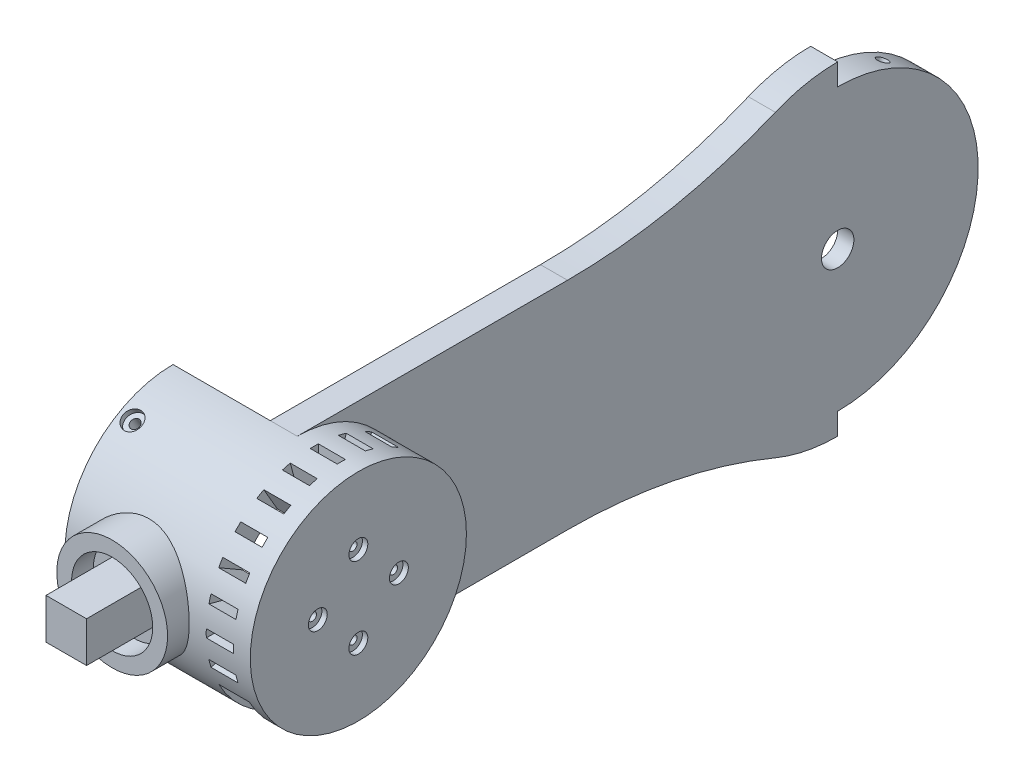
from build123d import *
from build123d.topology import SkipClean

# Parameters (mm, degrees)
SKETCH1_R                                            = 60
SKETCH1_R_2                                          = 45
SKETCH1_R_3                                          = 40
BOSS_EXTRUDE3_DEPTH                                  = 10
SKETCH5_R                                            = 30
CUT_EXTRUDE2_DEPTH                                   = 248.588368063
CUT_EXTRUDE2_DEPTH_BACK                              = 248.588368063
SKETCH6_R                                            = 18.5
CUT_EXTRUDE3_DEPTH                                   = 4
SKETCH7_R                                            = 40
SKETCH7_R_2                                          = 30
BOSS_EXTRUDE4_DEPTH                                  = 17.6
SKETCH8_R                                            = 40
BOSS_EXTRUDE5_DEPTH                                  = 5
SKETCH9_R                                            = 1.5
CUT_EXTRUDE4_DEPTH                                   = 249.921192348
CUT_EXTRUDE4_DEPTH_BACK                              = 249.921192348
BOSS_EXTRUDE6_DEPTH                                  = 31
BOSS_EXTRUDE8_REACH                                  = 309.673
SKETCH13_R                                           = 20.5
SKETCH16_W                                           = 15
SKETCH16_H                                           = 15
BOSS_EXTRUDE11_DEPTH                                 = 25
SKETCH17_R                                           = 15
BOSS_EXTRUDE12_DEPTH                                 = 8
SKETCH21_R                                           = 3.5
CUT_EXTRUDE5_DEPTH                                   = 2
BOSS_EXTRUDE13_DEPTH                                 = 5
CUT_EXTRUDE6_DEPTH                                   = 275.082104487
CBORE_FOR_M3_HEXAGON_HEAD_BOLTS_FULL_THR_D           = 3.4
CBORE_FOR_M3_HEXAGON_HEAD_BOLTS_FULL_THR_CBORE_D     = 7
CBORE_FOR_M3_HEXAGON_HEAD_BOLTS_FULL_THR_CBORE_DEPTH = 2
CBORE_FOR_M3_HEXAGON_HEAD_BOLTS_FULL_2_D             = 3.4
CBORE_FOR_M3_HEXAGON_HEAD_BOLTS_FULL_2_CBORE_D       = 7
CBORE_FOR_M3_HEXAGON_HEAD_BOLTS_FULL_2_CBORE_DEPTH   = 2
SKETCH33_R                                           = 2.05
CUT_EXTRUDE14_DEPTH                                  = 13
SKETCH34_R                                           = 2.05
CUT_EXTRUDE15_DEPTH                                  = 13
F_4_0MM_DOWEL_HOLE1_D                                = 4.1
F_4_0MM_DOWEL_HOLE1_DEPTH                            = 7
F_4_0MM_DOWEL_HOLE1_TIP                              = 1.231764269
F_4_0MM_DOWEL_HOLE1_ON_FACE_2_D                      = 4.1
F_4_0MM_DOWEL_HOLE1_ON_FACE_2_DEPTH                  = 7
F_4_0MM_DOWEL_HOLE1_ON_FACE_2_TIP                    = 1.231764269
SKETCH36_R                                           = 6
CUT_EXTRUDE16_DEPTH                                  = 2.5
CUT_EXTRUDE17_REACH                                  = 310.052
CUT_EXTRUDE17_END_RADIUS                             = 30
SKETCH37_W                                           = 10
SKETCH37_H                                           = 3
CIRPATTERN1_COUNT                                    = 24
CUT_EXTRUDE19_REACH                                  = 302.391
CUT_EXTRUDE19_END_RADIUS                             = 30
SKETCH39_W                                           = 11.3
SKETCH39_H                                           = 35
CUT_EXTRUDE20_REACH                                  = 255.253
CUT_EXTRUDE20_END_RADIUS                             = 30
SKETCH40_W                                           = 27.398821822
SKETCH40_H                                           = 15
CUT_EXTRUDE20_DIRECTION_2_REACH                      = 255.253
CUT_EXTRUDE20_DIRECTION_2_END_RADIUS                 = 34
CUT_EXTRUDE21_REACH                                  = 276.636
SKETCH41_R                                           = 6


with BuildPart() as part:
    # Sketch1 → Boss-Extrude3 (new body)
    with BuildSketch(Plane(origin=(0, 0, 0), x_dir=(0, 0, -1), z_dir=(1, 0, 0))):
        Circle(SKETCH1_R)
        Circle(SKETCH1_R_2, mode=Mode.SUBTRACT)
        with BuildLine():
            ThreePointArc((-23.076923077, 55.384615385), (-60.776772972, 43.883864862), (-100, 40))
            Line((-100, 40), (-200, 40))
            ThreePointArc((-200, 40), (-171.715728753, 28.284271247), (-160, 0))
            ThreePointArc((-160, 0), (-171.715728753, -28.284271247), (-200, -40))
            Line((-200, -40), (-100, -40))
            ThreePointArc((-100, -40), (-60.776772972, -43.883864862), (-23.076923077, -55.384615385))
            ThreePointArc((-23.076923077, -55.384615385), (-60, 0), (-23.076923077, 55.384615385))
        make_face()
        with Locations((-200, 0)):
            Circle(SKETCH1_R_3)
        Circle(SKETCH1_R_2)
    extrude(amount=BOSS_EXTRUDE3_DEPTH)

    # Sketch5 → Cut-Extrude2 (cut, two sides)
    with BuildSketch(Plane(origin=(10, 0, 0), x_dir=(0, 0, -1), z_dir=(1, 0, 0))) as cut_extrude2_sk:
        with Locations((-200, 0)):
            Circle(SKETCH5_R)
    extrude(amount=CUT_EXTRUDE2_DEPTH, mode=Mode.SUBTRACT)
    extrude(cut_extrude2_sk.sketch, amount=-CUT_EXTRUDE2_DEPTH_BACK, mode=Mode.SUBTRACT)

    # Sketch6 → Cut-Extrude3 (cut)
    with BuildSketch(Plane.ZY):
        Circle(SKETCH6_R)
    extrude(amount=-CUT_EXTRUDE3_DEPTH, mode=Mode.SUBTRACT)

    # Sketch7 → Boss-Extrude4 (add)
    with BuildSketch(Plane(origin=(10, 0, 0), x_dir=(0, 0, -1), z_dir=(1, 0, 0))):
        with Locations(Location((-200, 0, 0), (0, 0, 270))):
            Circle(SKETCH7_R)
        with Locations((-200, 0)):
            Circle(SKETCH7_R_2, mode=Mode.SUBTRACT)
    extrude(amount=BOSS_EXTRUDE4_DEPTH)

    # Sketch8 → Boss-Extrude5 (add)
    with BuildSketch(Plane(origin=(27.6, 0, 0), x_dir=(0, 0, -1), z_dir=(1, 0, 0))):
        with Locations(Location((-200, 0, 0), (0, 0, 270))):
            Circle(SKETCH8_R)
    extrude(amount=BOSS_EXTRUDE5_DEPTH)

    # Sketch9 → Cut-Extrude4 (cut, two sides)
    with BuildSketch(Plane.ZY.offset(-27.6)) as cut_extrude4_sk:
        with Locations((200, 15)):
            Circle(SKETCH9_R)
        with Locations((215, 0)):
            Circle(SKETCH9_R)
        with Locations((200, -15)):
            Circle(SKETCH9_R)
        with Locations((185, 0)):
            Circle(SKETCH9_R)
    extrude(amount=CUT_EXTRUDE4_DEPTH, mode=Mode.SUBTRACT)
    extrude(cut_extrude4_sk.sketch, amount=-CUT_EXTRUDE4_DEPTH_BACK, mode=Mode.SUBTRACT)

    # Sketch10 → Boss-Extrude6 (add)
    with BuildSketch(Plane.ZY):
        with BuildLine():
            Line((200, 40), (200, 30))
            ThreePointArc((200, 30), (230, 0), (200, -30))
            Line((200, -30), (200, -40))
            ThreePointArc((200, -40), (240, 0), (200, 40))
        make_face()
    extrude(amount=BOSS_EXTRUDE6_DEPTH)

    # Sketch13 → Boss-Extrude8 (add, up to next)
    with BuildSketch(Plane.XY.offset(240), mode=Mode.PRIVATE) as boss_extrude8_sk1:
        with Locations((-10.5, 0)):
            Circle(SKETCH13_R)
    boss_extrude8_tool1 = extrude(boss_extrude8_sk1.sketch, amount=-BOSS_EXTRUDE8_REACH, mode=Mode.PRIVATE) - part.part
    add(boss_extrude8_tool1.solids().sort_by_distance((-10.5, 0, 240))[0])
    add(boss_extrude8_tool1.solids().sort_by_distance((-10.5, 0, 240))[1])

    # Sketch16 → Boss-Extrude11 (add)
    with BuildSketch(Plane.XY.offset(240)):
        with Locations((-10.5, 0)):
            Rectangle(SKETCH16_W, SKETCH16_H)
    extrude(amount=BOSS_EXTRUDE11_DEPTH)

    # Sketch17 → Boss-Extrude12 (add)
    with BuildSketch(Plane.XY.offset(240)):
        with BuildLine():
            ThreePointArc((-31, 0), (-10.5, -20.5), (10, 0))
            ThreePointArc((10, 0), (-10.5, 20.5), (-31, 0))
        make_face()
        with Locations((-10.5, 0)):
            Circle(SKETCH17_R, mode=Mode.SUBTRACT)
    extrude(amount=BOSS_EXTRUDE12_DEPTH)

    # Sketch21 → Cut-Extrude5 (cut)
    with BuildSketch(Plane(origin=(32.6, 0, 0), x_dir=(0, 0, -1), z_dir=(1, 0, 0))):
        with Locations((-200, -15)):
            Circle(SKETCH21_R)
        with Locations((-215, 0)):
            Circle(SKETCH21_R)
        with Locations((-200, 15)):
            Circle(SKETCH21_R)
        with Locations((-185, 0)):
            Circle(SKETCH21_R)
    extrude(amount=-CUT_EXTRUDE5_DEPTH, mode=Mode.SUBTRACT)

    # Sketch23 → Boss-Extrude13 (add)
    with BuildSketch(Plane.ZY.offset(31)):
        with BuildLine():
            Line((200, 40), (200, 30))
            ThreePointArc((200, 30), (230, 0), (200, -30))
            Line((200, -30), (200, -40))
            ThreePointArc((200, -40), (228.284271247, -28.284271247), (240, 0))
            ThreePointArc((240, 0), (228.284271247, 28.284271247), (200, 40))
        make_face()
    extrude(amount=BOSS_EXTRUDE13_DEPTH)

    # Sketch24 → Cut-Extrude6 (cut, through all)
    with BuildSketch(Plane.ZY):
        with BuildLine():
            Line((0, 52), (0, 60))
            ThreePointArc((0, 60), (-60, 0), (0, -60))
            Line((0, -60), (0, -52))
            ThreePointArc((0, -52), (-52, 0), (0, 52))
        make_face()
    extrude(amount=-CUT_EXTRUDE6_DEPTH, mode=Mode.SUBTRACT)

    # CBORE for M3 Hexagon head bolts-Full thr (through all)
    with Locations(Plane(origin=(-31, 34.641016151, 220), x_dir=(0, -0.5, 0.866025403784), z_dir=(0, 0.866025403784, 0.5))):
        with Locations((0, 0)):
            CounterBoreHole(CBORE_FOR_M3_HEXAGON_HEAD_BOLTS_FULL_THR_D / 2, CBORE_FOR_M3_HEXAGON_HEAD_BOLTS_FULL_THR_CBORE_D / 2, CBORE_FOR_M3_HEXAGON_HEAD_BOLTS_FULL_THR_CBORE_DEPTH)

    # CBORE for M3 Hexagon head bolts-Full 2 (through all)
    with Locations(Plane(origin=(-31, -34.641016151, 220), x_dir=(0, -0.500000174844, -0.866025302838), z_dir=(0, -0.866025302838, 0.500000174844))):
        with Locations((0, 0)):
            CounterBoreHole(CBORE_FOR_M3_HEXAGON_HEAD_BOLTS_FULL_2_D / 2, CBORE_FOR_M3_HEXAGON_HEAD_BOLTS_FULL_2_CBORE_D / 2, CBORE_FOR_M3_HEXAGON_HEAD_BOLTS_FULL_2_CBORE_DEPTH)

    # Sketch33 → Cut-Extrude14 (cut)
    with BuildSketch(Plane(origin=(0, 52.725441887, -24.166666667), x_dir=(1, 0, 0), z_dir=(0, 0.9090593428863094, -0.416666666666667))):
        with Locations(Location((5, 0, 0), (0, 0, 270))):
            Circle(SKETCH33_R)
    extrude(amount=-CUT_EXTRUDE14_DEPTH, mode=Mode.SUBTRACT)

    # Sketch34 → Cut-Extrude15 (cut)
    with BuildSketch(Plane(origin=(0, -52.725441887, -24.166666667), x_dir=(-1, 0, 0), z_dir=(0, -0.9090593428863094, -0.416666666666667))):
        with Locations(Location((-5, 0, 0), (0, 0, 90))):
            Circle(SKETCH34_R)
    extrude(amount=-CUT_EXTRUDE15_DEPTH, mode=Mode.SUBTRACT)

    # 4.0mm Dowel Hole1
    with Locations(Plane(origin=(-12, -35, 200), x_dir=(-1, 0, 0), z_dir=(0, 0, -1))):
        with Locations((0, 0), (0, 70)):
            Hole(F_4_0MM_DOWEL_HOLE1_D / 2, depth=F_4_0MM_DOWEL_HOLE1_DEPTH)
            with Locations((0, 0, -(F_4_0MM_DOWEL_HOLE1_DEPTH + F_4_0MM_DOWEL_HOLE1_TIP / 2))):  # 118° drill point
                Cone(0, F_4_0MM_DOWEL_HOLE1_D / 2, F_4_0MM_DOWEL_HOLE1_TIP, mode=Mode.SUBTRACT)

    # 4.0mm Dowel Hole1 on face 2
    with Locations(Plane(origin=(-215.649554995, -58.553515583, 0), x_dir=(-1, 0, 0), z_dir=(0, 0, -1))):
        with Locations((0, 0)):
            Hole(F_4_0MM_DOWEL_HOLE1_ON_FACE_2_D / 2, depth=F_4_0MM_DOWEL_HOLE1_ON_FACE_2_DEPTH)
            with Locations((0, 0, -(F_4_0MM_DOWEL_HOLE1_ON_FACE_2_DEPTH + F_4_0MM_DOWEL_HOLE1_ON_FACE_2_TIP / 2))):  # 118° drill point
                Cone(0, F_4_0MM_DOWEL_HOLE1_ON_FACE_2_D / 2, F_4_0MM_DOWEL_HOLE1_ON_FACE_2_TIP, mode=Mode.SUBTRACT)

    # Sketch36 → Cut-Extrude16 (cut)
    with BuildSketch(Plane.ZY):
        with Locations((80, 25)):
            Circle(SKETCH36_R)
        with Locations((80, -25)):
            Circle(SKETCH36_R)
    extrude(amount=-CUT_EXTRUDE16_DEPTH, mode=Mode.SUBTRACT)

    # Cut-Extrude17: up to this cylinder (the profile starts outside it)
    cut_extrude17_end = Plane(origin=(21.3, 0, 200), z_dir=(1, 0, 0)) * Cylinder(CUT_EXTRUDE17_END_RADIUS, 681.104, mode=Mode.PRIVATE)
    # Sketch37 → Cut-Extrude17 (cut, up to the surface)
    with BuildSketch(Plane.XY.offset(248), mode=Mode.PRIVATE) as cut_extrude17_sk1:
        with Locations((21.3, 0)):
            Rectangle(SKETCH37_W, SKETCH37_H)
    cut_extrude17_tool1 = extrude(cut_extrude17_sk1.sketch, amount=-CUT_EXTRUDE17_REACH, mode=Mode.PRIVATE) - cut_extrude17_end
    cut_extrude17 = cut_extrude17_tool1.solids().sort_by_distance((21.3, 0, 248))[0]
    add(cut_extrude17, mode=Mode.SUBTRACT)

    # CirPattern1: Cut-Extrude17 ×24 about axis
    cirpattern1_axis = Axis((0, 0, 200), (1, 0, 0))
    for i in range(1, CIRPATTERN1_COUNT):
        add(cut_extrude17.rotate(cirpattern1_axis, i * 360 / CIRPATTERN1_COUNT), mode=Mode.SUBTRACT)

    # Cut-Extrude19: up to this cylinder (the profile starts outside it)
    with SkipClean():  # the faces are left unmerged after this step: merging them gives an invalid solid
        cut_extrude19_end = Plane(origin=(21.95, 0, 200), z_dir=(1, 0, 0)) * Cylinder(CUT_EXTRUDE19_END_RADIUS, 665.782, mode=Mode.PRIVATE)
        # Sketch39 → Cut-Extrude19 (cut, up to the surface)
        with BuildSketch(Plane(origin=(26.3, -28.284271247, 228.284271247), x_dir=(1, 0, 0), z_dir=(0, -0.7071067811865382, 0.7071067811865568)), mode=Mode.PRIVATE) as cut_extrude19_sk1:
            with Locations((-4.35, -5.705631303)):
                Rectangle(SKETCH39_W, SKETCH39_H)
        cut_extrude19_tool1 = extrude(cut_extrude19_sk1.sketch, amount=-CUT_EXTRUDE19_REACH, mode=Mode.PRIVATE) - cut_extrude19_end
        add(cut_extrude19_tool1.solids().sort_by_distance((21.95, -32.318762, 224.249781))[0], mode=Mode.SUBTRACT)

    # Cut-Extrude20: up to this cylinder (the profile starts outside it)
    with SkipClean():  # the faces are left unmerged after this step: merging them gives an invalid solid
        cut_extrude20_end = Plane(origin=(2.600589, 0, 200), z_dir=(1, 0, 0)) * Cylinder(CUT_EXTRUDE20_END_RADIUS, 571.506, mode=Mode.PRIVATE)
        # Sketch40 → Cut-Extrude20 (cut, up to the surface)
        with BuildSketch(Plane(origin=(0, -121.213203436, 121.213203436), x_dir=(-1, 0, 0), z_dir=(0, 0.7071067811865382, -0.7071067811865568)), mode=Mode.PRIVATE) as cut_extrude20_sk1:
            with Locations((-2.600589089, 135.37344337)):
                Rectangle(SKETCH40_W, SKETCH40_H)
        cut_extrude20_tool1 = extrude(cut_extrude20_sk1.sketch, amount=CUT_EXTRUDE20_REACH, mode=Mode.PRIVATE) - cut_extrude20_end
        add(cut_extrude20_tool1.solids().sort_by_distance((2.600589, -25.489724, 216.936683))[0], mode=Mode.SUBTRACT)
        add(cut_extrude20_tool1.solids().sort_by_distance((2.600589, -25.489724, 216.936683))[1], mode=Mode.SUBTRACT)

    # Cut-Extrude20 direction 2: up to this cylinder (the profile starts inside it)
    with SkipClean():  # the faces are left unmerged after this step: merging them gives an invalid solid
        cut_extrude20_direction_2_end = Plane(origin=(2.600589, 0, 200), z_dir=(-1, 0, 0)) * Cylinder(CUT_EXTRUDE20_DIRECTION_2_END_RADIUS, 579.506, mode=Mode.PRIVATE)
        # Sketch40 → Cut-Extrude20 direction 2 (cut, up to the surface)
        with BuildSketch(Plane(origin=(0, -121.213203436, 121.213203436), x_dir=(-1, 0, 0), z_dir=(0, 0.7071067811865382, -0.7071067811865568)), mode=Mode.PRIVATE) as cut_extrude20_direction_2_sk1:
            with Locations((-2.600589089, 135.37344337)):
                Rectangle(SKETCH40_W, SKETCH40_H)
        cut_extrude20_direction_2_tool1 = extrude(cut_extrude20_direction_2_sk1.sketch, amount=-CUT_EXTRUDE20_DIRECTION_2_REACH, mode=Mode.PRIVATE) & cut_extrude20_direction_2_end
        add(cut_extrude20_direction_2_tool1.solids().sort_by_distance((2.600589, -25.489724, 216.936683))[0], mode=Mode.SUBTRACT)

    # Sketch41 → Cut-Extrude21 (cut, up to next)
    with BuildSketch(Plane.ZY.offset(-4), mode=Mode.PRIVATE) as cut_extrude21_sk1:
        Circle(SKETCH41_R)
    cut_extrude21_tool1 = extrude(cut_extrude21_sk1.sketch, amount=-CUT_EXTRUDE21_REACH, mode=Mode.PRIVATE) & part.part
    add(cut_extrude21_tool1.solids().sort_by_distance((4, 0, 0))[0], mode=Mode.SUBTRACT)


solid = part.part
